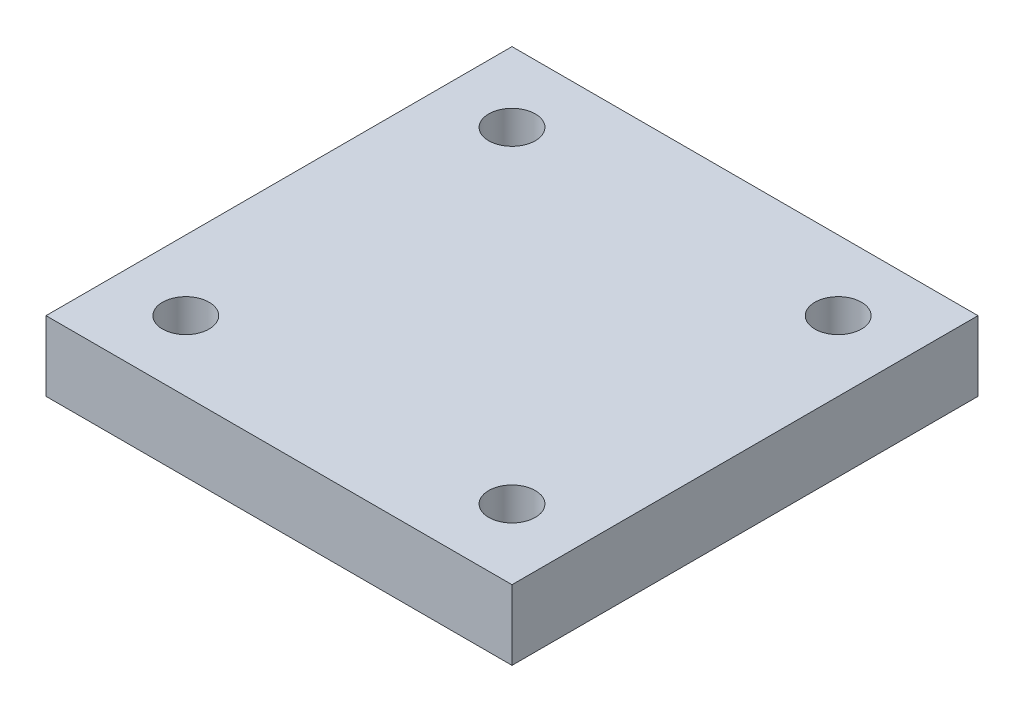
from build123d import *

# Parameters (mm, degrees)
SKETCH1_R           = 6
BOSS_EXTRUDE1_DEPTH = 22
SKETCH2_W           = 100
SKETCH2_H           = 100
SKETCH2_R           = 5
BOSS_EXTRUDE2_DEPTH = 15


with BuildPart() as part:
    # Sketch1 → Boss-Extrude1 (new body)
    with BuildSketch(Plane(origin=(0, 0, 0), x_dir=(1, 0, 0), z_dir=(0, 1, 0))):
        Circle(SKETCH1_R)
    extrude(amount=BOSS_EXTRUDE1_DEPTH)

    # Sketch2 → Boss-Extrude2 (add)
    with BuildSketch(Plane(origin=(0, 22, 0), x_dir=(1, 0, 0), z_dir=(0, 1, 0))):
        Rectangle(SKETCH2_W, SKETCH2_H)
        with Locations((-35, 35)):
            Circle(SKETCH2_R, mode=Mode.SUBTRACT)
        with Locations((35, 35)):
            Circle(SKETCH2_R, mode=Mode.SUBTRACT)
        with Locations((35, -35)):
            Circle(SKETCH2_R, mode=Mode.SUBTRACT)
        with Locations((-35, -35)):
            Circle(SKETCH2_R, mode=Mode.SUBTRACT)
    extrude(amount=BOSS_EXTRUDE2_DEPTH)


solid = part.part
